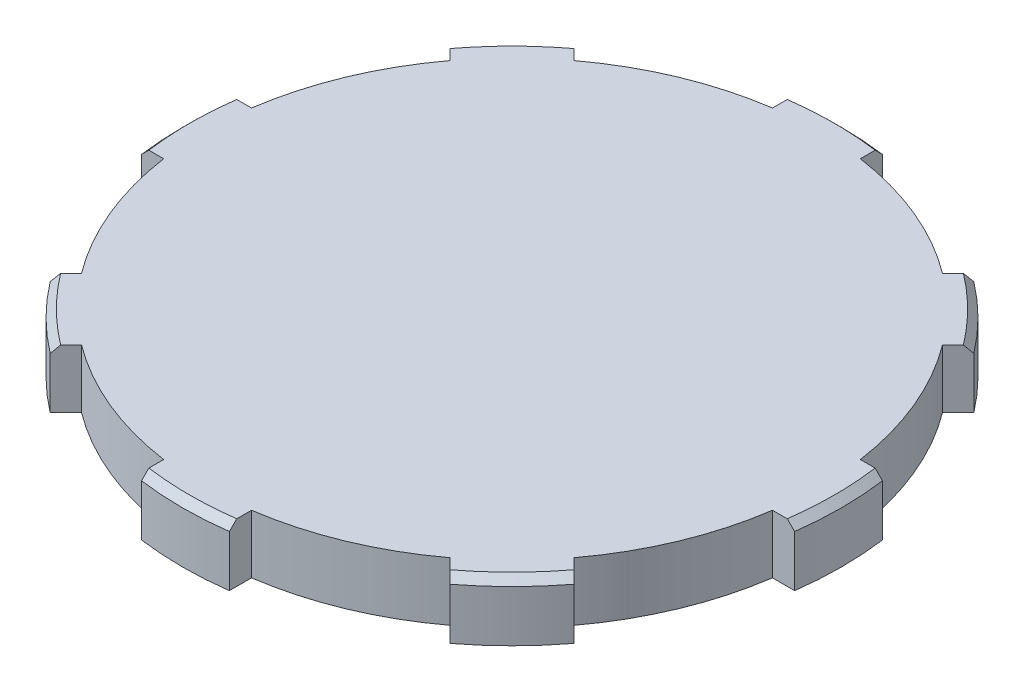
from build123d import *

# Parameters (mm, degrees)
SKETCH_1_R               = 21
EXTRUDE_1_DEPTH          = 4
EXTRUDE_2_DEPTH          = 4
PATTERN_CIRCULAR_1_COUNT = 8
CHAMFER_1_SIZE           = 0.5


with BuildPart() as part:
    # 草图1 → 凸台-拉伸1 (new body)
    with BuildSketch(Plane(origin=(0, 0, 0), x_dir=(1, 0, 0), z_dir=(0, 1, 0))):
        Circle(SKETCH_1_R)
    extrude(amount=EXTRUDE_1_DEPTH)

    # 草图2 → 凸台-拉伸2 (add)
    with BuildSketch(Plane(origin=(0, 4, 0), x_dir=(1, 0, 0), z_dir=(0, 1, 0))):
        with BuildLine():
            Line((-22.299103121, 3), (22.299103121, 3))
            ThreePointArc((22.299103121, 3), (22.5, 0), (22.299103121, -3))
            Line((22.299103121, -3), (-22.299103121, -3))
            ThreePointArc((-22.299103121, -3), (-22.5, 0), (-22.299103121, 3))
        make_face()
    extrude_2 = extrude(amount=-EXTRUDE_2_DEPTH)

    # 阵列(圆周)1: 凸台-拉伸2 ×8 about axis
    pattern_circular_1_axis = Axis((0, 0, 0), (0, 1, 0))
    for i in range(1, PATTERN_CIRCULAR_1_COUNT):
        add(extrude_2.rotate(pattern_circular_1_axis, i * 360 / PATTERN_CIRCULAR_1_COUNT))

    # 倒角1
    chamfer_1_edges = [part.edges().sort_by_distance(p)[0] for p in [
        (22.5, 4, 0),
        (-22.5, 4, 0),
        (15.909902577, 4, -15.909902577),
        (0, 4, -22.5),
        (-15.909902577, 4, -15.909902577),
        (15.909902577, 4, 15.909902577),
        (-15.909902577, 4, 15.909902577),
        (0, 4, 22.5),
    ]]
    chamfer(chamfer_1_edges, length=CHAMFER_1_SIZE)


solid = part.part
